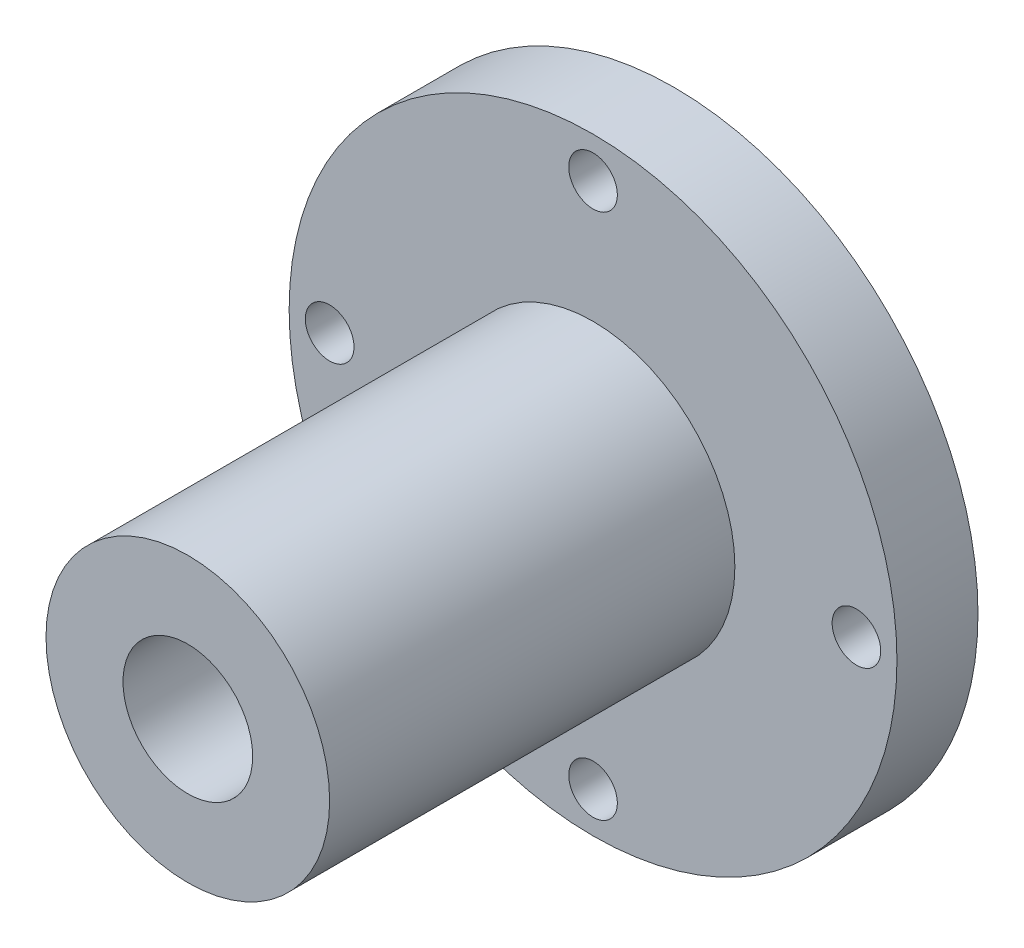
from build123d import *

# Parameters (mm, degrees)
SKETCH_1_R          = 37.5
EXTRUDE_1_DEPTH     = 10
SKETCH_2_R          = 17.5
EXTRUDE_2_DEPTH     = 50
SKETCH_3_R          = 8
CUT_EXTRUDE_1_DEPTH = 61
SKETCH_4_R          = 3
CUT_EXTRUDE_2_DEPTH = 10


with BuildPart() as part:
    # 草图1 → 凸台-拉伸1 (new body)
    with BuildSketch(Plane.XY):
        Circle(SKETCH_1_R)
    extrude(amount=EXTRUDE_1_DEPTH)

    # 草图2 → 凸台-拉伸2 (add)
    with BuildSketch(Plane.XY.offset(10)):
        Circle(SKETCH_2_R)
    extrude(amount=EXTRUDE_2_DEPTH)

    # 草图3 → 切除-拉伸1 (cut, through all)
    with BuildSketch(Plane.XY.offset(60)):
        Circle(SKETCH_3_R)
    extrude(amount=-CUT_EXTRUDE_1_DEPTH, mode=Mode.SUBTRACT)

    # 草图4 → 切除-拉伸2 (cut)
    with BuildSketch(Plane.XY.offset(10)):
        with Locations((0, 32.5)):
            Circle(SKETCH_4_R)
        with Locations((32.5, 0)):
            Circle(SKETCH_4_R)
        with Locations((0, -32.5)):
            Circle(SKETCH_4_R)
        with Locations((-32.5, 0)):
            Circle(SKETCH_4_R)
    extrude(amount=-CUT_EXTRUDE_2_DEPTH, mode=Mode.SUBTRACT)


solid = part.part
